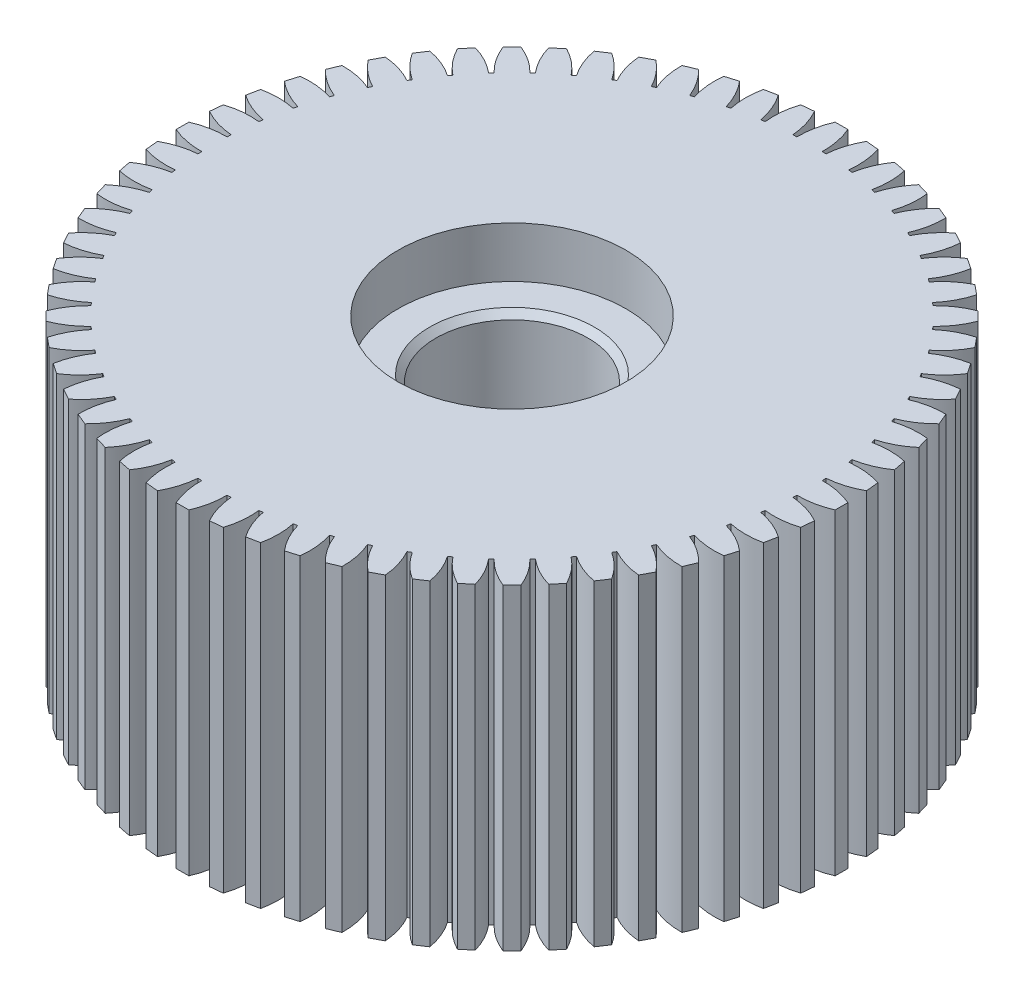
from build123d import *

# Parameters (mm, degrees)
SKETCH2_R           = 23.5
BOSS_EXTRUDE1_DEPTH = 25
BOSS_EXTRUDE2_DEPTH = 25
SKETCH4_R           = 9
CUT_EXTRUDE1_DEPTH  = 4
SKETCH5_R           = 6
CUT_EXTRUDE2_DEPTH  = 30
CHAMFER2_SIZE       = 0.5
CHAMFER3_SIZE       = 0.5


with BuildPart() as part:
    # Sketch2 → Boss-Extrude1 (new body)
    with BuildSketch(Plane(origin=(0, 0, 0), x_dir=(1, 0, 0), z_dir=(0, 1, 0))):
        Circle(SKETCH2_R)
    extrude(amount=BOSS_EXTRUDE1_DEPTH)

    # Sketch3 → Boss-Extrude2 (add)
    with BuildSketch(Plane(origin=(0, 25, 0), x_dir=(1, 0, 0), z_dir=(0, 1, 0))):
        with BuildLine():
            Line((0.5, 25.995191863), (-0.5, 25.995191863))
            ThreePointArc((-0.5, 25.995191863), (-0.886082796, 24.763991156), (-1, 23.478713764))
            ThreePointArc((-1, 23.478713764), (0, 23.5), (1, 23.478713764))
            ThreePointArc((1, 23.478713764), (0.886082796, 24.763991156), (0.5, 25.995191863))
        make_face()
        with BuildLine():
            ThreePointArc((-1.306131655, 23.46367448), (-1.545479531, 24.731597072), (-2.050382005, 25.919026479))
            Line((-2.050382005, 25.919026479), (-3.045566732, 25.821009339))
            ThreePointArc((-3.045566732, 25.821009339), (-3.309111661, 24.557894469), (-3.296501108, 23.267640199))
            ThreePointArc((-3.296501108, 23.267640199), (-2.303402798, 23.386841077), (-1.306131655, 23.46367448))
        make_face()
        with BuildLine():
            Line((3.045566732, 25.821009339), (2.050382005, 25.919026479))
            ThreePointArc((2.050382005, 25.919026479), (1.545479531, 24.731597072), (1.306131655, 23.46367448))
            ThreePointArc((1.306131655, 23.46367448), (2.303402798, 23.386841077), (3.296501108, 23.267640199))
            ThreePointArc((3.296501108, 23.267640199), (3.309111661, 24.557894469), (3.045566732, 25.821009339))
        make_face()
        with BuildLine():
            ThreePointArc((-3.599684548, 23.222667184), (-3.962158046, 24.461024188), (-4.581017711, 25.593246702))
            Line((-4.581017711, 25.593246702), (-5.561802992, 25.39815638))
            ThreePointArc((-5.561802992, 25.39815638), (-5.700271973, 24.115291832), (-5.561255109, 22.83248654))
            ThreePointArc((-5.561255109, 22.83248654), (-4.584622567, 23.048454089), (-3.599684548, 23.222667184))
        make_face()
        with BuildLine():
            Line((5.561802992, 25.39815638), (4.581017711, 25.593246702))
            ThreePointArc((4.581017711, 25.593246702), (3.962158046, 24.461024188), (3.599684548, 23.222667184))
            ThreePointArc((3.599684548, 23.222667184), (4.584622567, 23.048454089), (5.561255109, 22.83248654))
            ThreePointArc((5.561255109, 22.83248654), (5.700271973, 24.115291832), (5.561802992, 25.39815638))
        make_face()
        with BuildLine():
            ThreePointArc((-5.858570512, 22.758012909), (-6.340678812, 23.95487827), (-7.067535712, 25.020989968))
            Line((-7.067535712, 25.020989968), (-8.024476048, 24.73070529))
            ThreePointArc((-8.024476048, 24.73070529), (-8.036535549, 23.440445753), (-7.772451183, 22.177443554))
            ThreePointArc((-7.772451183, 22.177443554), (-6.821689915, 22.48809789), (-5.858570512, 22.758012909))
        make_face()
        with BuildLine():
            Line((8.024476048, 24.73070529), (7.067535712, 25.020989968))
            ThreePointArc((7.067535712, 25.020989968), (6.340678812, 23.95487827), (5.858570512, 22.758012909))
            ThreePointArc((5.858570512, 22.758012909), (6.821689915, 22.48809789), (7.772451183, 22.177443554))
            ThreePointArc((7.772451183, 22.177443554), (8.036535549, 23.440445753), (8.024476048, 24.73070529))
        make_face()
        with BuildLine():
            ThreePointArc((-8.061035238, 22.074186528), (-8.658135375, 23.218033778), (-9.485989481, 24.207767422))
            Line((-9.485989481, 24.207767422), (-10.409869013, 23.82508399))
            ThreePointArc((-10.409869013, 23.82508399), (-10.295402894, 22.539855367), (-9.908794303, 21.308819664))
            ThreePointArc((-9.908794303, 21.308819664), (-8.993060661, 21.711169014), (-8.061035238, 22.074186528))
        make_face()
        with BuildLine():
            Line((10.409869013, 23.82508399), (9.485989481, 24.207767422))
            ThreePointArc((9.485989481, 24.207767422), (8.658135375, 23.218033778), (8.061035238, 22.074186528))
            ThreePointArc((8.061035238, 22.074186528), (8.993060661, 21.711169014), (9.908794303, 21.308819664))
            ThreePointArc((9.908794303, 21.308819664), (10.295402894, 22.539855367), (10.409869013, 23.82508399))
        make_face()
        with BuildLine():
            ThreePointArc((-10.185867789, 21.177773665), (-10.892209362, 22.25758693), (-11.813087985, 23.161410843))
            Line((-11.813087985, 23.161410843), (-12.69500925, 22.690014106))
            ThreePointArc((-12.69500925, 22.690014106), (-12.455119882, 21.422193852), (-11.949710317, 20.234980191))
            ThreePointArc((-11.949710317, 20.234980191), (-11.077823315, 20.725149712), (-10.185867789, 21.177773665))
        make_face()
        with BuildLine():
            Line((12.69500925, 22.690014106), (11.813087985, 23.161410843))
            ThreePointArc((11.813087985, 23.161410843), (10.892209362, 22.25758693), (10.185867789, 21.177773665))
            ThreePointArc((10.185867789, 21.177773665), (11.077823315, 20.725149712), (11.949710317, 20.234980191))
            ThreePointArc((11.949710317, 20.234980191), (12.455119882, 21.422193852), (12.69500925, 22.690014106))
        make_face()
        with BuildLine():
            ThreePointArc((-12.212604864, 20.077407264), (-13.021385418, 21.082787351), (-14.026419995, 21.891997217))
            Line((-14.026419995, 21.891997217), (-14.857889607, 21.336426984))
            ThreePointArc((-14.857889607, 21.336426984), (-14.494887256, 20.0982249), (-13.875544089, 18.966266797))
            ThreePointArc((-13.875544089, 18.966266797), (-13.055900476, 19.539535889), (-12.212604864, 20.077407264))
        make_face()
        with BuildLine():
            Line((14.857889607, 21.336426984), (14.026419995, 21.891997217))
            ThreePointArc((14.026419995, 21.891997217), (13.021385418, 21.082787351), (12.212604864, 20.077407264))
            ThreePointArc((12.212604864, 20.077407264), (13.055900476, 19.539535889), (13.875544089, 18.966266797))
            ThreePointArc((13.875544089, 18.966266797), (14.494887256, 20.0982249), (14.857889607, 21.336426984))
        make_face()
        with BuildLine():
            ThreePointArc((-14.121727879, 18.783684455), (-15.025158415, 19.704949006), (-16.104669912, 20.411751689))
            Line((-16.104669912, 20.411751689), (-16.877680365, 19.777358405))
            ThreePointArc((-16.877680365, 19.777358405), (-16.395060943, 18.580699056), (-15.667748786, 17.514897887))
            ThreePointArc((-15.667748786, 17.514897887), (-14.908242178, 18.165745654), (-14.121727879, 18.783684455))
        make_face()
        with BuildLine():
            Line((16.877680365, 19.777358405), (16.104669912, 20.411751689))
            ThreePointArc((16.104669912, 20.411751689), (15.025158415, 19.704949006), (14.121727879, 18.783684455))
            ThreePointArc((14.121727879, 18.783684455), (14.908242178, 18.165745654), (15.667748786, 17.514897887))
            ThreePointArc((15.667748786, 17.514897887), (16.395060943, 18.580699056), (16.877680365, 19.777358405))
        make_face()
        with BuildLine():
            ThreePointArc((-15.894850935, 17.309064497), (-16.884230922, 18.13734123), (-18.027823054, 18.734929835))
            Line((-18.027823054, 18.734929835), (-18.734929835, 18.027823054))
            ThreePointArc((-18.734929835, 18.027823054), (-18.13734123, 16.884230922), (-17.309064497, 15.894850935))
            ThreePointArc((-17.309064497, 15.894850935), (-16.617009358, 16.617009358), (-15.894850935, 17.309064497))
        make_face()
        with BuildLine():
            Line((18.734929835, 18.027823054), (18.027823054, 18.734929835))
            ThreePointArc((18.027823054, 18.734929835), (16.884230922, 18.13734123), (15.894850935, 17.309064497))
            ThreePointArc((15.894850935, 17.309064497), (16.617009358, 16.617009358), (17.309064497, 15.894850935))
            ThreePointArc((17.309064497, 15.894850935), (18.13734123, 16.884230922), (18.734929835, 18.027823054))
        make_face()
        with BuildLine():
            ThreePointArc((-17.514897887, 15.667748786), (-18.580699056, 16.395060943), (-19.777358405, 16.877680365))
            Line((-19.777358405, 16.877680365), (-20.411751689, 16.104669912))
            ThreePointArc((-20.411751689, 16.104669912), (-19.704949006, 15.025158415), (-18.783684455, 14.121727879))
            ThreePointArc((-18.783684455, 14.121727879), (-18.165745654, 14.908242178), (-17.514897887, 15.667748786))
        make_face()
        with BuildLine():
            Line((20.411751689, 16.104669912), (19.777358405, 16.877680365))
            ThreePointArc((19.777358405, 16.877680365), (18.580699056, 16.395060943), (17.514897887, 15.667748786))
            ThreePointArc((17.514897887, 15.667748786), (18.165745654, 14.908242178), (18.783684455, 14.121727879))
            ThreePointArc((18.783684455, 14.121727879), (19.704949006, 15.025158415), (20.411751689, 16.104669912))
        make_face()
        with BuildLine():
            ThreePointArc((-18.966266797, 13.875544089), (-20.0982249, 14.494887256), (-21.336426984, 14.857889607))
            Line((-21.336426984, 14.857889607), (-21.891997217, 14.026419995))
            ThreePointArc((-21.891997217, 14.026419995), (-21.082787351, 13.021385418), (-20.077407264, 12.212604864))
            ThreePointArc((-20.077407264, 12.212604864), (-19.539535889, 13.055900476), (-18.966266797, 13.875544089))
        make_face()
        with BuildLine():
            Line((21.891997217, 14.026419995), (21.336426984, 14.857889607))
            ThreePointArc((21.336426984, 14.857889607), (20.0982249, 14.494887256), (18.966266797, 13.875544089))
            ThreePointArc((18.966266797, 13.875544089), (19.539535889, 13.055900476), (20.077407264, 12.212604864))
            ThreePointArc((20.077407264, 12.212604864), (21.082787351, 13.021385418), (21.891997217, 14.026419995))
        make_face()
        with BuildLine():
            ThreePointArc((-20.234980191, 11.949710317), (-21.422193852, 12.455119882), (-22.690014106, 12.69500925))
            Line((-22.690014106, 12.69500925), (-23.161410843, 11.813087985))
            ThreePointArc((-23.161410843, 11.813087985), (-22.25758693, 10.892209362), (-21.177773665, 10.185867789))
            ThreePointArc((-21.177773665, 10.185867789), (-20.725149712, 11.077823315), (-20.234980191, 11.949710317))
        make_face()
        with BuildLine():
            Line((23.161410843, 11.813087985), (22.690014106, 12.69500925))
            ThreePointArc((22.690014106, 12.69500925), (21.422193852, 12.455119882), (20.234980191, 11.949710317))
            ThreePointArc((20.234980191, 11.949710317), (20.725149712, 11.077823315), (21.177773665, 10.185867789))
            ThreePointArc((21.177773665, 10.185867789), (22.25758693, 10.892209362), (23.161410843, 11.813087985))
        make_face()
        with BuildLine():
            ThreePointArc((-21.308819664, 9.908794303), (-22.539855367, 10.295402894), (-23.82508399, 10.409869013))
            Line((-23.82508399, 10.409869013), (-24.207767422, 9.485989481))
            ThreePointArc((-24.207767422, 9.485989481), (-23.218033778, 8.658135375), (-22.074186528, 8.061035238))
            ThreePointArc((-22.074186528, 8.061035238), (-21.711169014, 8.993060661), (-21.308819664, 9.908794303))
        make_face()
        with BuildLine():
            Line((24.207767422, 9.485989481), (23.82508399, 10.409869013))
            ThreePointArc((23.82508399, 10.409869013), (22.539855367, 10.295402894), (21.308819664, 9.908794303))
            ThreePointArc((21.308819664, 9.908794303), (21.711169014, 8.993060661), (22.074186528, 8.061035238))
            ThreePointArc((22.074186528, 8.061035238), (23.218033778, 8.658135375), (24.207767422, 9.485989481))
        make_face()
        with BuildLine():
            ThreePointArc((-22.177443554, 7.772451183), (-23.440445753, 8.036535549), (-24.73070529, 8.024476048))
            Line((-24.73070529, 8.024476048), (-25.020989968, 7.067535712))
            ThreePointArc((-25.020989968, 7.067535712), (-23.95487827, 6.340678812), (-22.758012909, 5.858570512))
            ThreePointArc((-22.758012909, 5.858570512), (-22.48809789, 6.821689915), (-22.177443554, 7.772451183))
        make_face()
        with BuildLine():
            Line((25.020989968, 7.067535712), (24.73070529, 8.024476048))
            ThreePointArc((24.73070529, 8.024476048), (23.440445753, 8.036535549), (22.177443554, 7.772451183))
            ThreePointArc((22.177443554, 7.772451183), (22.48809789, 6.821689915), (22.758012909, 5.858570512))
            ThreePointArc((22.758012909, 5.858570512), (23.95487827, 6.340678812), (25.020989968, 7.067535712))
        make_face()
        with BuildLine():
            ThreePointArc((-22.83248654, 5.561255109), (-24.115291832, 5.700271973), (-25.39815638, 5.561802992))
            Line((-25.39815638, 5.561802992), (-25.593246702, 4.581017711))
            ThreePointArc((-25.593246702, 4.581017711), (-24.461024188, 3.962158046), (-23.222667184, 3.599684548))
            ThreePointArc((-23.222667184, 3.599684548), (-23.048454089, 4.584622567), (-22.83248654, 5.561255109))
        make_face()
        with BuildLine():
            Line((25.593246702, 4.581017711), (25.39815638, 5.561802992))
            ThreePointArc((25.39815638, 5.561802992), (24.115291832, 5.700271973), (22.83248654, 5.561255109))
            ThreePointArc((22.83248654, 5.561255109), (23.048454089, 4.584622567), (23.222667184, 3.599684548))
            ThreePointArc((23.222667184, 3.599684548), (24.461024188, 3.962158046), (25.593246702, 4.581017711))
        make_face()
        with BuildLine():
            ThreePointArc((-23.267640199, 3.296501108), (-24.557894469, 3.309111661), (-25.821009339, 3.045566732))
            Line((-25.821009339, 3.045566732), (-25.919026479, 2.050382005))
            ThreePointArc((-25.919026479, 2.050382005), (-24.731597072, 1.545479531), (-23.46367448, 1.306131655))
            ThreePointArc((-23.46367448, 1.306131655), (-23.386841077, 2.303402798), (-23.267640199, 3.296501108))
        make_face()
        with BuildLine():
            Line((25.919026479, 2.050382005), (25.821009339, 3.045566732))
            ThreePointArc((25.821009339, 3.045566732), (24.557894469, 3.309111661), (23.267640199, 3.296501108))
            ThreePointArc((23.267640199, 3.296501108), (23.386841077, 2.303402798), (23.46367448, 1.306131655))
            ThreePointArc((23.46367448, 1.306131655), (24.731597072, 1.545479531), (25.919026479, 2.050382005))
        make_face()
        with BuildLine():
            ThreePointArc((-23.478713764, 1), (-24.763991156, 0.886082796), (-25.995191863, 0.5))
            Line((-25.995191863, 0.5), (-25.995191863, -0.5))
            ThreePointArc((-25.995191863, -0.5), (-24.763991156, -0.886082796), (-23.478713764, -1))
            ThreePointArc((-23.478713764, -1), (-23.5, 0), (-23.478713764, 1))
        make_face()
        with BuildLine():
            Line((25.995191863, -0.5), (25.995191863, 0.5))
            ThreePointArc((25.995191863, 0.5), (24.763991156, 0.886082796), (23.478713764, 1))
            ThreePointArc((23.478713764, 1), (23.5, 0), (23.478713764, -1))
            ThreePointArc((23.478713764, -1), (24.763991156, -0.886082796), (25.995191863, -0.5))
        make_face()
        with BuildLine():
            ThreePointArc((-23.46367448, -1.306131655), (-24.731597072, -1.545479531), (-25.919026479, -2.050382005))
            Line((-25.919026479, -2.050382005), (-25.821009339, -3.045566732))
            ThreePointArc((-25.821009339, -3.045566732), (-24.557894469, -3.309111661), (-23.267640199, -3.296501108))
            ThreePointArc((-23.267640199, -3.296501108), (-23.386841077, -2.303402798), (-23.46367448, -1.306131655))
        make_face()
        with BuildLine():
            Line((25.821009339, -3.045566732), (25.919026479, -2.050382005))
            ThreePointArc((25.919026479, -2.050382005), (24.731597072, -1.545479531), (23.46367448, -1.306131655))
            ThreePointArc((23.46367448, -1.306131655), (23.386841077, -2.303402798), (23.267640199, -3.296501108))
            ThreePointArc((23.267640199, -3.296501108), (24.557894469, -3.309111661), (25.821009339, -3.045566732))
        make_face()
        with BuildLine():
            ThreePointArc((-23.222667184, -3.599684548), (-24.461024188, -3.962158046), (-25.593246702, -4.581017711))
            Line((-25.593246702, -4.581017711), (-25.39815638, -5.561802992))
            ThreePointArc((-25.39815638, -5.561802992), (-24.115291832, -5.700271973), (-22.83248654, -5.561255109))
            ThreePointArc((-22.83248654, -5.561255109), (-23.048454089, -4.584622567), (-23.222667184, -3.599684548))
        make_face()
        with BuildLine():
            Line((25.39815638, -5.561802992), (25.593246702, -4.581017711))
            ThreePointArc((25.593246702, -4.581017711), (24.461024188, -3.962158046), (23.222667184, -3.599684548))
            ThreePointArc((23.222667184, -3.599684548), (23.048454089, -4.584622567), (22.83248654, -5.561255109))
            ThreePointArc((22.83248654, -5.561255109), (24.115291832, -5.700271973), (25.39815638, -5.561802992))
        make_face()
        with BuildLine():
            ThreePointArc((-22.758012909, -5.858570512), (-23.95487827, -6.340678812), (-25.020989968, -7.067535712))
            Line((-25.020989968, -7.067535712), (-24.73070529, -8.024476048))
            ThreePointArc((-24.73070529, -8.024476048), (-23.440445753, -8.036535549), (-22.177443554, -7.772451183))
            ThreePointArc((-22.177443554, -7.772451183), (-22.48809789, -6.821689915), (-22.758012909, -5.858570512))
        make_face()
        with BuildLine():
            Line((24.73070529, -8.024476048), (25.020989968, -7.067535712))
            ThreePointArc((25.020989968, -7.067535712), (23.95487827, -6.340678812), (22.758012909, -5.858570512))
            ThreePointArc((22.758012909, -5.858570512), (22.48809789, -6.821689915), (22.177443554, -7.772451183))
            ThreePointArc((22.177443554, -7.772451183), (23.440445753, -8.036535549), (24.73070529, -8.024476048))
        make_face()
        with BuildLine():
            ThreePointArc((-22.074186528, -8.061035238), (-23.218033778, -8.658135375), (-24.207767422, -9.485989481))
            Line((-24.207767422, -9.485989481), (-23.82508399, -10.409869013))
            ThreePointArc((-23.82508399, -10.409869013), (-22.539855367, -10.295402894), (-21.308819664, -9.908794303))
            ThreePointArc((-21.308819664, -9.908794303), (-21.711169014, -8.993060661), (-22.074186528, -8.061035238))
        make_face()
        with BuildLine():
            Line((23.82508399, -10.409869013), (24.207767422, -9.485989481))
            ThreePointArc((24.207767422, -9.485989481), (23.218033778, -8.658135375), (22.074186528, -8.061035238))
            ThreePointArc((22.074186528, -8.061035238), (21.711169014, -8.993060661), (21.308819664, -9.908794303))
            ThreePointArc((21.308819664, -9.908794303), (22.539855367, -10.295402894), (23.82508399, -10.409869013))
        make_face()
        with BuildLine():
            ThreePointArc((-21.177773665, -10.185867789), (-22.25758693, -10.892209362), (-23.161410843, -11.813087985))
            Line((-23.161410843, -11.813087985), (-22.690014106, -12.69500925))
            ThreePointArc((-22.690014106, -12.69500925), (-21.422193852, -12.455119882), (-20.234980191, -11.949710317))
            ThreePointArc((-20.234980191, -11.949710317), (-20.725149712, -11.077823315), (-21.177773665, -10.185867789))
        make_face()
        with BuildLine():
            Line((22.690014106, -12.69500925), (23.161410843, -11.813087985))
            ThreePointArc((23.161410843, -11.813087985), (22.25758693, -10.892209362), (21.177773665, -10.185867789))
            ThreePointArc((21.177773665, -10.185867789), (20.725149712, -11.077823315), (20.234980191, -11.949710317))
            ThreePointArc((20.234980191, -11.949710317), (21.422193852, -12.455119882), (22.690014106, -12.69500925))
        make_face()
        with BuildLine():
            ThreePointArc((-20.077407264, -12.212604864), (-21.082787351, -13.021385418), (-21.891997217, -14.026419995))
            Line((-21.891997217, -14.026419995), (-21.336426984, -14.857889607))
            ThreePointArc((-21.336426984, -14.857889607), (-20.0982249, -14.494887256), (-18.966266797, -13.875544089))
            ThreePointArc((-18.966266797, -13.875544089), (-19.539535889, -13.055900476), (-20.077407264, -12.212604864))
        make_face()
        with BuildLine():
            Line((21.336426984, -14.857889607), (21.891997217, -14.026419995))
            ThreePointArc((21.891997217, -14.026419995), (21.082787351, -13.021385418), (20.077407264, -12.212604864))
            ThreePointArc((20.077407264, -12.212604864), (19.539535889, -13.055900476), (18.966266797, -13.875544089))
            ThreePointArc((18.966266797, -13.875544089), (20.0982249, -14.494887256), (21.336426984, -14.857889607))
        make_face()
        with BuildLine():
            ThreePointArc((-18.783684455, -14.121727879), (-19.704949006, -15.025158415), (-20.411751689, -16.104669912))
            Line((-20.411751689, -16.104669912), (-19.777358405, -16.877680365))
            ThreePointArc((-19.777358405, -16.877680365), (-18.580699056, -16.395060943), (-17.514897887, -15.667748786))
            ThreePointArc((-17.514897887, -15.667748786), (-18.165745654, -14.908242178), (-18.783684455, -14.121727879))
        make_face()
        with BuildLine():
            Line((19.777358405, -16.877680365), (20.411751689, -16.104669912))
            ThreePointArc((20.411751689, -16.104669912), (19.704949006, -15.025158415), (18.783684455, -14.121727879))
            ThreePointArc((18.783684455, -14.121727879), (18.165745654, -14.908242178), (17.514897887, -15.667748786))
            ThreePointArc((17.514897887, -15.667748786), (18.580699056, -16.395060943), (19.777358405, -16.877680365))
        make_face()
        with BuildLine():
            ThreePointArc((-17.309064497, -15.894850935), (-18.13734123, -16.884230922), (-18.734929835, -18.027823054))
            Line((-18.734929835, -18.027823054), (-18.027823054, -18.734929835))
            ThreePointArc((-18.027823054, -18.734929835), (-16.884230922, -18.13734123), (-15.894850935, -17.309064497))
            ThreePointArc((-15.894850935, -17.309064497), (-16.617009358, -16.617009358), (-17.309064497, -15.894850935))
        make_face()
        with BuildLine():
            Line((18.027823054, -18.734929835), (18.734929835, -18.027823054))
            ThreePointArc((18.734929835, -18.027823054), (18.13734123, -16.884230922), (17.309064497, -15.894850935))
            ThreePointArc((17.309064497, -15.894850935), (16.617009358, -16.617009358), (15.894850935, -17.309064497))
            ThreePointArc((15.894850935, -17.309064497), (16.884230922, -18.13734123), (18.027823054, -18.734929835))
        make_face()
        with BuildLine():
            ThreePointArc((-15.667748786, -17.514897887), (-16.395060943, -18.580699056), (-16.877680365, -19.777358405))
            Line((-16.877680365, -19.777358405), (-16.104669912, -20.411751689))
            ThreePointArc((-16.104669912, -20.411751689), (-15.025158415, -19.704949006), (-14.121727879, -18.783684455))
            ThreePointArc((-14.121727879, -18.783684455), (-14.908242178, -18.165745654), (-15.667748786, -17.514897887))
        make_face()
        with BuildLine():
            Line((16.104669912, -20.411751689), (16.877680365, -19.777358405))
            ThreePointArc((16.877680365, -19.777358405), (16.395060943, -18.580699056), (15.667748786, -17.514897887))
            ThreePointArc((15.667748786, -17.514897887), (14.908242178, -18.165745654), (14.121727879, -18.783684455))
            ThreePointArc((14.121727879, -18.783684455), (15.025158415, -19.704949006), (16.104669912, -20.411751689))
        make_face()
        with BuildLine():
            ThreePointArc((-13.875544089, -18.966266797), (-14.494887256, -20.0982249), (-14.857889607, -21.336426984))
            Line((-14.857889607, -21.336426984), (-14.026419995, -21.891997217))
            ThreePointArc((-14.026419995, -21.891997217), (-13.021385418, -21.082787351), (-12.212604864, -20.077407264))
            ThreePointArc((-12.212604864, -20.077407264), (-13.055900476, -19.539535889), (-13.875544089, -18.966266797))
        make_face()
        with BuildLine():
            Line((14.026419995, -21.891997217), (14.857889607, -21.336426984))
            ThreePointArc((14.857889607, -21.336426984), (14.494887256, -20.0982249), (13.875544089, -18.966266797))
            ThreePointArc((13.875544089, -18.966266797), (13.055900476, -19.539535889), (12.212604864, -20.077407264))
            ThreePointArc((12.212604864, -20.077407264), (13.021385418, -21.082787351), (14.026419995, -21.891997217))
        make_face()
        with BuildLine():
            ThreePointArc((-11.949710317, -20.234980191), (-12.455119882, -21.422193852), (-12.69500925, -22.690014106))
            Line((-12.69500925, -22.690014106), (-11.813087985, -23.161410843))
            ThreePointArc((-11.813087985, -23.161410843), (-10.892209362, -22.25758693), (-10.185867789, -21.177773665))
            ThreePointArc((-10.185867789, -21.177773665), (-11.077823315, -20.725149712), (-11.949710317, -20.234980191))
        make_face()
        with BuildLine():
            Line((11.813087985, -23.161410843), (12.69500925, -22.690014106))
            ThreePointArc((12.69500925, -22.690014106), (12.455119882, -21.422193852), (11.949710317, -20.234980191))
            ThreePointArc((11.949710317, -20.234980191), (11.077823315, -20.725149712), (10.185867789, -21.177773665))
            ThreePointArc((10.185867789, -21.177773665), (10.892209362, -22.25758693), (11.813087985, -23.161410843))
        make_face()
        with BuildLine():
            ThreePointArc((-9.908794303, -21.308819664), (-10.295402894, -22.539855367), (-10.409869013, -23.82508399))
            Line((-10.409869013, -23.82508399), (-9.485989481, -24.207767422))
            ThreePointArc((-9.485989481, -24.207767422), (-8.658135375, -23.218033778), (-8.061035238, -22.074186528))
            ThreePointArc((-8.061035238, -22.074186528), (-8.993060661, -21.711169014), (-9.908794303, -21.308819664))
        make_face()
        with BuildLine():
            Line((9.485989481, -24.207767422), (10.409869013, -23.82508399))
            ThreePointArc((10.409869013, -23.82508399), (10.295402894, -22.539855367), (9.908794303, -21.308819664))
            ThreePointArc((9.908794303, -21.308819664), (8.993060661, -21.711169014), (8.061035238, -22.074186528))
            ThreePointArc((8.061035238, -22.074186528), (8.658135375, -23.218033778), (9.485989481, -24.207767422))
        make_face()
        with BuildLine():
            ThreePointArc((-7.772451183, -22.177443554), (-8.036535549, -23.440445753), (-8.024476048, -24.73070529))
            Line((-8.024476048, -24.73070529), (-7.067535712, -25.020989968))
            ThreePointArc((-7.067535712, -25.020989968), (-6.340678812, -23.95487827), (-5.858570512, -22.758012909))
            ThreePointArc((-5.858570512, -22.758012909), (-6.821689915, -22.48809789), (-7.772451183, -22.177443554))
        make_face()
        with BuildLine():
            Line((7.067535712, -25.020989968), (8.024476048, -24.73070529))
            ThreePointArc((8.024476048, -24.73070529), (8.036535549, -23.440445753), (7.772451183, -22.177443554))
            ThreePointArc((7.772451183, -22.177443554), (6.821689915, -22.48809789), (5.858570512, -22.758012909))
            ThreePointArc((5.858570512, -22.758012909), (6.340678812, -23.95487827), (7.067535712, -25.020989968))
        make_face()
        with BuildLine():
            ThreePointArc((-5.561255109, -22.83248654), (-5.700271973, -24.115291832), (-5.561802992, -25.39815638))
            Line((-5.561802992, -25.39815638), (-4.581017711, -25.593246702))
            ThreePointArc((-4.581017711, -25.593246702), (-3.962158046, -24.461024188), (-3.599684548, -23.222667184))
            ThreePointArc((-3.599684548, -23.222667184), (-4.584622567, -23.048454089), (-5.561255109, -22.83248654))
        make_face()
        with BuildLine():
            Line((4.581017711, -25.593246702), (5.561802992, -25.39815638))
            ThreePointArc((5.561802992, -25.39815638), (5.700271973, -24.115291832), (5.561255109, -22.83248654))
            ThreePointArc((5.561255109, -22.83248654), (4.584622567, -23.048454089), (3.599684548, -23.222667184))
            ThreePointArc((3.599684548, -23.222667184), (3.962158046, -24.461024188), (4.581017711, -25.593246702))
        make_face()
        with BuildLine():
            ThreePointArc((-3.296501108, -23.267640199), (-3.309111661, -24.557894469), (-3.045566732, -25.821009339))
            Line((-3.045566732, -25.821009339), (-2.050382005, -25.919026479))
            ThreePointArc((-2.050382005, -25.919026479), (-1.545479531, -24.731597072), (-1.306131655, -23.46367448))
            ThreePointArc((-1.306131655, -23.46367448), (-2.303402798, -23.386841077), (-3.296501108, -23.267640199))
        make_face()
        with BuildLine():
            Line((2.050382005, -25.919026479), (3.045566732, -25.821009339))
            ThreePointArc((3.045566732, -25.821009339), (3.309111661, -24.557894469), (3.296501108, -23.267640199))
            ThreePointArc((3.296501108, -23.267640199), (2.303402798, -23.386841077), (1.306131655, -23.46367448))
            ThreePointArc((1.306131655, -23.46367448), (1.545479531, -24.731597072), (2.050382005, -25.919026479))
        make_face()
        with BuildLine():
            ThreePointArc((-1, -23.478713764), (-0.886082796, -24.763991156), (-0.5, -25.995191863))
            Line((-0.5, -25.995191863), (0.5, -25.995191863))
            ThreePointArc((0.5, -25.995191863), (0.886082796, -24.763991156), (1, -23.478713764))
            ThreePointArc((1, -23.478713764), (0, -23.5), (-1, -23.478713764))
        make_face()
    extrude(amount=-BOSS_EXTRUDE2_DEPTH)

    # Sketch4 → Cut-Extrude1 (cut)
    with BuildSketch(Plane(origin=(0, 25, 0), x_dir=(1, 0, 0), z_dir=(0, 1, 0))):
        Circle(SKETCH4_R)
    extrude(amount=-CUT_EXTRUDE1_DEPTH, mode=Mode.SUBTRACT)

    # Sketch5 → Cut-Extrude2 (cut)
    with BuildSketch(Plane(origin=(0, 25, 0), x_dir=(1, 0, 0), z_dir=(0, 1, 0))):
        Circle(SKETCH5_R)
    extrude(amount=-CUT_EXTRUDE2_DEPTH, mode=Mode.SUBTRACT)

    # Chamfer2
    chamfer2_edges = [part.edges().sort_by_distance(p)[0] for p in [
        (-6, 21, 0),
    ]]
    chamfer(chamfer2_edges, length=CHAMFER2_SIZE)

    # Chamfer3
    chamfer3_edges = [part.edges().sort_by_distance(p)[0] for p in [
        (-6, 0, 0),
    ]]
    chamfer(chamfer3_edges, length=CHAMFER3_SIZE)


solid = part.part
